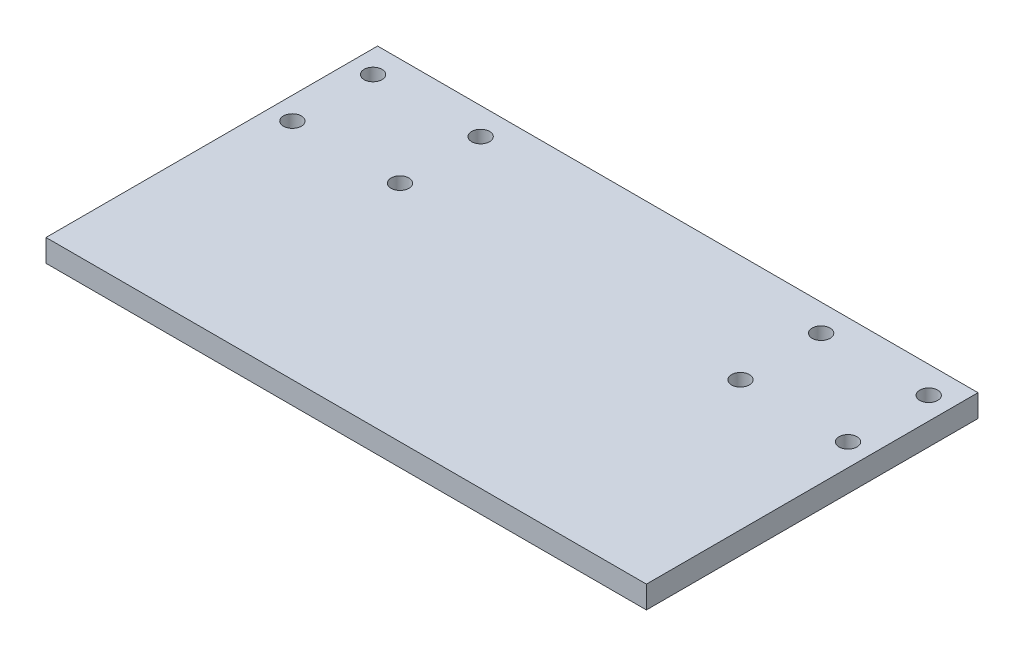
from build123d import *

# Parameters (mm, degrees)
SKETCH2_W           = 134
SKETCH2_H           = 74
BOSS_EXTRUDE1_DEPTH = 5
SKETCH3_R           = 2
CUT_EXTRUDE1_DEPTH  = 6


with BuildPart() as part:
    # Sketch2 → Boss-Extrude1 (new body)
    with BuildSketch(Plane(origin=(0, 0, 0), x_dir=(1, 0, 0), z_dir=(0, 1, 0))):
        with Locations((9.034606205, 24.563245823)):
            Rectangle(SKETCH2_W, SKETCH2_H)
    extrude(amount=BOSS_EXTRUDE1_DEPTH)

    # Sketch3 → Cut-Extrude1 (cut, through all)
    with BuildSketch(Plane(origin=(0, 5, 0), x_dir=(1, 0, 0), z_dir=(0, 1, 0))):
        with Locations((71.034606205, 55.563245823)):
            Circle(SKETCH3_R)
        with Locations((47.034607673, 55.554851462)):
            Circle(SKETCH3_R)
        with Locations((71.034606205, 37.563245823)):
            Circle(SKETCH3_R)
        with Locations((47.034607673, 37.554851462)):
            Circle(SKETCH3_R)
        with Locations((-28.965393795, 37.563245823)):
            Circle(SKETCH3_R)
        with Locations((-52.965392327, 37.554851462)):
            Circle(SKETCH3_R)
        with Locations((-52.965392327, 55.554851462)):
            Circle(SKETCH3_R)
        with Locations((-28.965393795, 55.563245823)):
            Circle(SKETCH3_R)
    extrude(amount=-CUT_EXTRUDE1_DEPTH, mode=Mode.SUBTRACT)


solid = part.part
